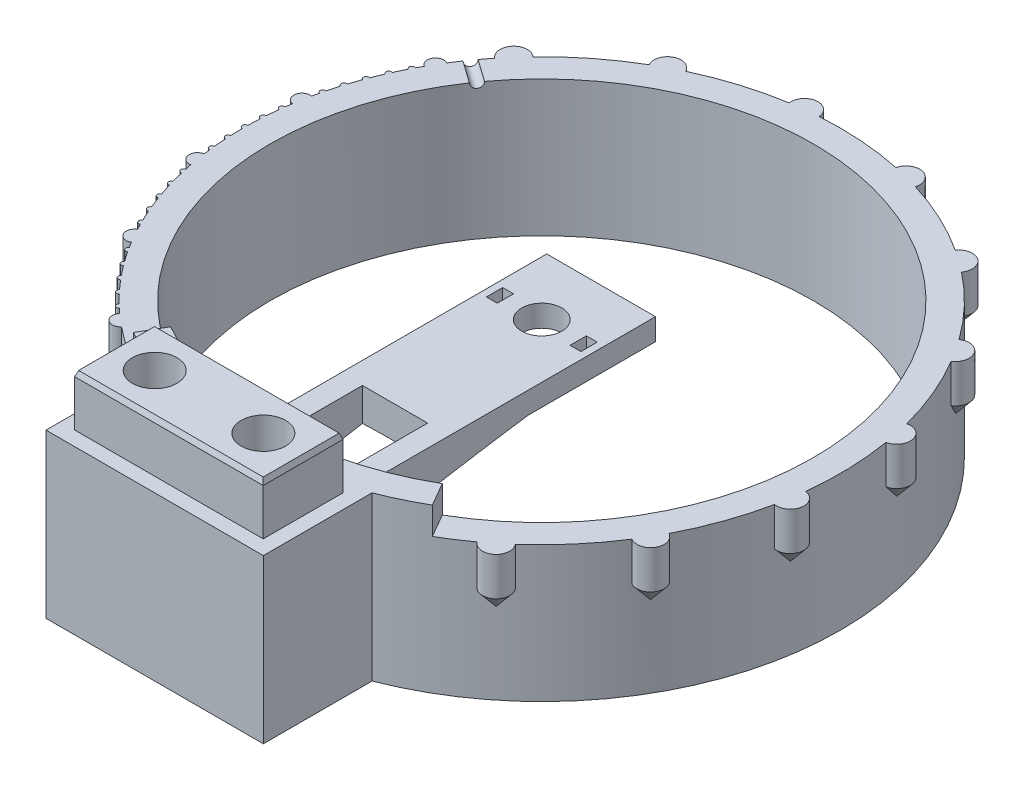
from build123d import *

# Parameters (mm, degrees)
SKETCH1_R              = 55
BOSS_EXTRUDE1_DEPTH    = 30
SKETCH6_R              = 50
CUT_EXTRUDE3_DEPTH     = 31
CUT_EXTRUDE4_DEPTH     = 5
BOSS_EXTRUDE3_START    = -7
BOSS_EXTRUDE3_DEPTH    = 4
SKETCH9_W              = 40
SKETCH9_H              = 20
BOSS_EXTRUDE4_DEPTH    = 30
SKETCH10_R             = 3.7
SKETCH10_W             = 2
SKETCH10_H             = 3
CUT_EXTRUDE5_DEPTH     = 23
CHAMFER2_SIZE          = 6
CHAMFER2_SIZE2         = 34.027690918
SKETCH11_R             = 4.1
CUT_EXTRUDE6_DEPTH     = 31
SKETCH12_R             = 1.5
SKETCH12_R_2           = 0.5
SKETCH12_R_3           = 2.5
BOSS_EXTRUDE5_DEPTH    = 10
SKETCH14_W             = 12
SKETCH14_H             = 20
CUT_EXTRUDE7_DEPTH     = 23.0000001
SKETCH15_W             = 34.7
SKETCH15_H             = 14.7
SKETCH15_R             = 4.1
BOSS_EXTRUDE6_DEPTH    = 9.5
CHAMFER3_SIZE          = 1
CHAMFER3_SIZE2         = 0.363970234
CHAMFER3_PART_2_SIZE   = 1
CHAMFER3_PART_2_SIZE2  = 0.363970234
CHAMFER3_PART_3_SIZE   = 1
CHAMFER3_PART_3_SIZE2  = 0.363970234
CHAMFER3_PART_4_SIZE   = 1
CHAMFER3_PART_4_SIZE2  = 0.363970234
SKETCH16_W             = 35
SKETCH16_H             = 15
CUT_EXTRUDE8_DEPTH     = 10
CHAMFER4_SIZE          = 1
CHAMFER4_SIZE2         = 2.747477419
CHAMFER5_SIZE          = 2.45
CHAMFER5_SIZE2         = 2.919796302
CHAMFER5_PART_2_SIZE   = 2.45
CHAMFER5_PART_2_SIZE2  = 2.919796302
CHAMFER5_PART_3_SIZE   = 2.45
CHAMFER5_PART_3_SIZE2  = 2.919796302
CHAMFER5_PART_4_SIZE   = 2.45
CHAMFER5_PART_4_SIZE2  = 2.919796302
CHAMFER5_PART_5_SIZE   = 2.45
CHAMFER5_PART_5_SIZE2  = 2.919796302
CHAMFER5_PART_6_SIZE   = 2.45
CHAMFER5_PART_6_SIZE2  = 2.919796302
CHAMFER5_PART_7_SIZE   = 2.45
CHAMFER5_PART_7_SIZE2  = 2.919796302
CHAMFER5_PART_8_SIZE   = 2.45
CHAMFER5_PART_8_SIZE2  = 2.919796302
CHAMFER5_PART_9_SIZE   = 2.45
CHAMFER5_PART_9_SIZE2  = 2.919796302
CHAMFER5_PART_10_SIZE  = 2.45
CHAMFER5_PART_10_SIZE2 = 2.919796302


with BuildPart() as part:
    # Sketch1 → Boss-Extrude1 (new body)
    with BuildSketch(Plane(origin=(0, 0, 0), x_dir=(1, 0, 0), z_dir=(0, 1, 0))):
        with Locations(Location((0, 0, 0), (0, 0, 270))):  # turned: the seam where the file's is
            Circle(SKETCH1_R)
    extrude(amount=BOSS_EXTRUDE1_DEPTH)

    # Sketch6 → Cut-Extrude3 (cut, through all)
    with BuildSketch(Plane(origin=(0, 30, 0), x_dir=(1, 0, 0), z_dir=(0, 1, 0))):
        with Locations(Location((0, 0, 0), (0, 0, 270))):  # turned: the seam where the file's is
            Circle(SKETCH6_R)
    extrude(amount=-CUT_EXTRUDE3_DEPTH, mode=Mode.SUBTRACT)

    # Sketch7 → Cut-Extrude4 (cut)
    with BuildSketch(Plane(origin=(0, 30, 0), x_dir=(1, 0, 0), z_dir=(0, 1, 0))):
        with BuildLine():
            Line((-25, -43.301270189), (-27.5, -47.631397208))
            ThreePointArc((-27.5, -47.631397208), (0, 55), (27.5, -47.631397208))
            Line((27.5, -47.631397208), (25, -43.301270189))
            ThreePointArc((25, -43.301270189), (0, 50), (-25, -43.301270189))
        make_face()
    extrude(amount=-CUT_EXTRUDE4_DEPTH, mode=Mode.SUBTRACT)

    # Sketch8 → Boss-Extrude3 (add)
    with BuildSketch(Plane(origin=(0, 25, 0), x_dir=(1, 0, 0), z_dir=(0, 1, 0)).offset(BOSS_EXTRUDE3_START)):
        with BuildLine():
            Line((10, -54.083269132), (10, 10.916730868))
            Line((10, 10.916730868), (-10, 10.916730868))
            Line((-10, 10.916730868), (-10, -54.083269132))
            ThreePointArc((-10, -54.083269132), (0, -55), (10, -54.083269132))
        make_face()
    extrude(amount=BOSS_EXTRUDE3_DEPTH)

    # Sketch9 → Boss-Extrude4 (add)
    with BuildSketch(Plane.XZ):
        with Locations((0, 61.23475383)):
            Rectangle(SKETCH9_W, SKETCH9_H)
    extrude(amount=-BOSS_EXTRUDE4_DEPTH)

    # Sketch10 → Cut-Extrude5 (cut, through all)
    with BuildSketch(Plane(origin=(0, 22, 0), x_dir=(1, 0, 0), z_dir=(0, 1, 0))):
        with Locations(Location((0, 0, 0), (0, 0, 270))):  # turned: the seam where the file's is
            Circle(SKETCH10_R)
        with Locations((7.7, 0)):
            Rectangle(SKETCH10_W, SKETCH10_H)
        with Locations((-7.7, 0)):
            Rectangle(SKETCH10_W, SKETCH10_H)
    extrude(amount=-CUT_EXTRUDE5_DEPTH, mode=Mode.SUBTRACT)

    # Chamfer2
    chamfer2_edges = [part.edges().sort_by_distance(p)[0] for p in [
        (5.0254481, 18, 49.74680765),
    ]]
    chamfer2_side = [part.faces().sort_by_distance(p)[0] for p in [
        (0, 15, -50),
    ]]
    chamfer(chamfer2_edges, length=CHAMFER2_SIZE, length2=CHAMFER2_SIZE2, reference=chamfer2_side[0])

    # Sketch11 → Cut-Extrude6 (cut, through all)
    with BuildSketch(Plane(origin=(0, 30, 0), x_dir=(1, 0, 0), z_dir=(0, 1, 0))):
        with Locations(Location((-10, -61.23475383, 0), (0, 0, 270))):  # turned: the seam where the file's is
            Circle(SKETCH11_R)
        with Locations(Location((10, -61.23475383, 0), (0, 0, 270))):  # turned: the seam where the file's is
            Circle(SKETCH11_R)
    extrude(amount=-CUT_EXTRUDE6_DEPTH, mode=Mode.SUBTRACT)

    # Sketch12 → Boss-Extrude5 (add)
    with BuildSketch(Plane(origin=(0, 25, 0), x_dir=(1, 0, 0), z_dir=(0, 1, 0))):
        with Locations((-35.669848164, -41.864805409)):
            Circle(SKETCH12_R)
        with Locations((-47.837299851, -27.140242132)):
            Circle(SKETCH12_R)
        with Locations((-54.234867172, -9.142165107)):
            Circle(SKETCH12_R)
        with Locations((-54.090909091, 9.958591955)):
            Circle(SKETCH12_R)
        with Locations((-47.422789077, 27.858195853)):
            Circle(SKETCH12_R)
        with Locations((-38.043722374, -39.719959566)):
            Circle(SKETCH12_R_2)
        with Locations((-40.288868671, -37.440713952)):
            Circle(SKETCH12_R_2)
        with Locations((-42.397690188, -35.034780814)):
            Circle(SKETCH12_R_2)
        with Locations((-44.363051343, -32.510301068)):
            Circle(SKETCH12_R_2)
        with Locations((-46.178301975, -29.875816753)):
            Circle(SKETCH12_R_2)
        with Locations((-49.334431446, -24.312833523)):
            Circle(SKETCH12_R_2)
        with Locations((-50.664630942, -21.403157981)):
            Circle(SKETCH12_R_2)
        with Locations((-51.823397364, -18.421060927)):
            Circle(SKETCH12_R_2)
        with Locations((-52.806809814, -15.376632834)):
            Circle(SKETCH12_R_2)
        with Locations((-53.611540735, -12.280175083)):
            Circle(SKETCH12_R_2)
        with Locations((-54.674679987, -5.973220938)):
            Circle(SKETCH12_R_2)
        with Locations((-54.929490991, -2.78406528)):
            Circle(SKETCH12_R_2)
        with Locations((-54.998437985, 0.414510774)):
            Circle(SKETCH12_R_2)
        with Locations((-54.881287675, 3.611684254)):
            Circle(SKETCH12_R_2)
        with Locations((-54.578436459, 6.796636939)):
            Circle(SKETCH12_R_2)
        with Locations((-53.420355208, 13.086850248)):
            Circle(SKETCH12_R_2)
        with Locations((-52.569043754, 16.170826782)):
            Circle(SKETCH12_R_2)
        with Locations((-51.539855295, 19.200086358)):
            Circle(SKETCH12_R_2)
        with Locations((-50.336272281, 22.164378919)):
            Circle(SKETCH12_R_2)
        with Locations((-48.962367255, 25.053674238)):
            Circle(SKETCH12_R_2)
        with Locations((-41.383539223, 36.227098716)):
            Circle(SKETCH12_R_3)
        with Locations((-25.557835394, 48.701099064)):
            Circle(SKETCH12_R_3)
        with Locations((-6.301437111, 54.637824722)):
            Circle(SKETCH12_R_3)
        with Locations((13.8008194, 53.240373627)):
            Circle(SKETCH12_R_3)
        with Locations((32.05055617, 44.696329258)):
            Circle(SKETCH12_R_3)
        with Locations((45.998063758, 30.152580826)):
            Circle(SKETCH12_R_3)
        with Locations((53.771132088, 11.561373358)):
            Circle(SKETCH12_R_3)
        with Locations((54.326362062, -8.581747205)):
            Circle(SKETCH12_R_3)
        with Locations((47.589223722, -27.57291761)):
            Circle(SKETCH12_R_3)
        with Locations((34.4640606, -42.862903856)):
            Circle(SKETCH12_R_3)
    extrude(amount=-BOSS_EXTRUDE5_DEPTH)

    # Sketch13 → Cut-Revolve1 (revolve, cut)
    with BuildSketch(Plane(origin=(0, 25, 0), x_dir=(1, 0, 0), z_dir=(0, 1, 0))):
        Polygon((-38.04336201, 25.705402511), (-46.205304558, 31.483178366), (-45.627526973, 32.299372621), (-37.465584424, 26.521596766), align=None)
    revolve(axis=Axis((-44.890684017, 25, -31.777767205), (0.816194255, 0, 0.577777586)), mode=Mode.SUBTRACT)

    # Sketch14 → Cut-Extrude7 (cut, through all)
    with BuildSketch(Plane(origin=(0, 22, 0), x_dir=(1, 0, 0), z_dir=(0, 1, 0))):
        with Locations((0, -37)):
            Rectangle(SKETCH14_W, SKETCH14_H)
    extrude(amount=-CUT_EXTRUDE7_DEPTH, mode=Mode.SUBTRACT)

    # Sketch15 → Boss-Extrude6 (add)
    with BuildSketch(Plane(origin=(0, 30, 0), x_dir=(1, 0, 0), z_dir=(0, 1, 0))):
        with Locations((-0.026221239, -61.23475383)):
            Rectangle(SKETCH15_W, SKETCH15_H)
        with Locations(Location((-10, -61.23475383, 0), (0, 0, 270))):  # turned: the seam where the file's is
            Circle(SKETCH15_R, mode=Mode.SUBTRACT)
        with Locations(Location((10, -61.23475383, 0), (0, 0, 270))):  # turned: the seam where the file's is
            Circle(SKETCH15_R, mode=Mode.SUBTRACT)
    extrude(amount=BOSS_EXTRUDE6_DEPTH)

    # Chamfer3
    chamfer3_edges = [part.edges().sort_by_distance(p)[0] for p in [
        (-17.376221239, 39.5, 61.23475383),
    ]]
    chamfer3_side = [part.faces().sort_by_distance(p)[0] for p in [
        (-17.376221239, 34.75, 61.23475383),
    ]]
    chamfer(chamfer3_edges, length=CHAMFER3_SIZE, length2=CHAMFER3_SIZE2, reference=chamfer3_side[0])

    # Chamfer3 part 2
    chamfer3_part_2_edges = [part.edges().sort_by_distance(p)[0] for p in [
        (-0.026221239, 39.5, 68.58475383),
    ]]
    chamfer3_part_2_side = [part.faces().sort_by_distance(p)[0] for p in [
        (-0.026221239, 34.75, 68.58475383),
    ]]
    chamfer(chamfer3_part_2_edges, length=CHAMFER3_PART_2_SIZE, length2=CHAMFER3_PART_2_SIZE2, reference=chamfer3_part_2_side[0])

    # Chamfer3 part 3
    chamfer3_part_3_edges = [part.edges().sort_by_distance(p)[0] for p in [
        (17.323778761, 39.5, 61.23475383),
    ]]
    chamfer3_part_3_side = [part.faces().sort_by_distance(p)[0] for p in [
        (17.323778761, 34.75, 61.23475383),
    ]]
    chamfer(chamfer3_part_3_edges, length=CHAMFER3_PART_3_SIZE, length2=CHAMFER3_PART_3_SIZE2, reference=chamfer3_part_3_side[0])

    # Chamfer3 part 4
    chamfer3_part_4_edges = [part.edges().sort_by_distance(p)[0] for p in [
        (-0.026221239, 39.5, 53.88475383),
    ]]
    chamfer3_part_4_side = [part.faces().sort_by_distance(p)[0] for p in [
        (-0.026221239, 34.75, 53.88475383),
    ]]
    chamfer(chamfer3_part_4_edges, length=CHAMFER3_PART_4_SIZE, length2=CHAMFER3_PART_4_SIZE2, reference=chamfer3_part_4_side[0])

    # Sketch16 → Cut-Extrude8 (cut)
    with BuildSketch(Plane.XZ):
        with Locations((0, 61.23475383)):
            Rectangle(SKETCH16_W, SKETCH16_H)
    extrude(amount=-CUT_EXTRUDE8_DEPTH, mode=Mode.SUBTRACT)

    # Chamfer4
    chamfer4_edges = [part.edges().sort_by_distance(p)[0] for p in [
        (17.5, 0, 61.23475383),
        (0, 0, 68.73475383),
        (-17.5, 0, 61.23475383),
        (0, 0, 53.73475383),
    ]]
    chamfer4_side = [part.faces().sort_by_distance(p)[0] for p in [
        (-18.325628086, 0, 61.23475383),
    ]]
    chamfer(chamfer4_edges, length=CHAMFER4_SIZE, length2=CHAMFER4_SIZE2, reference=chamfer4_side[0])

    # Chamfer5
    chamfer5_edges = [part.edges().sort_by_distance(p)[0] for p in [
        (-43.264609188, 15, -37.873785021),
    ]]
    chamfer5_side = [part.faces().sort_by_distance(p)[0] for p in [
        (-42.174140054, 15, -36.919189699),
    ]]
    chamfer(chamfer5_edges, length=CHAMFER5_SIZE, length2=CHAMFER5_SIZE2, reference=chamfer5_side[0])

    # Chamfer5 part 2
    chamfer5_part_2_edges = [part.edges().sort_by_distance(p)[0] for p in [
        (-26.719555184, 15, -50.914785385),
    ]]
    chamfer5_part_2_side = [part.faces().sort_by_distance(p)[0] for p in [
        (-26.04609827, 15, -49.631496272),
    ]]
    chamfer(chamfer5_part_2_edges, length=CHAMFER5_PART_2_SIZE, length2=CHAMFER5_PART_2_SIZE2, reference=chamfer5_part_2_side[0])

    # Chamfer5 part 3
    chamfer5_part_3_edges = [part.edges().sort_by_distance(p)[0] for p in [
        (-6.58786607, 15, -57.121362209),
    ]]
    chamfer5_part_3_side = [part.faces().sort_by_distance(p)[0] for p in [
        (-6.421821242, 15, -55.681638528),
    ]]
    chamfer(chamfer5_part_3_edges, length=CHAMFER5_PART_3_SIZE, length2=CHAMFER5_PART_3_SIZE2, reference=chamfer5_part_3_side[0])

    # Chamfer5 part 4
    chamfer5_part_4_edges = [part.edges().sort_by_distance(p)[0] for p in [
        (14.428129372, 15, -55.66039061),
    ]]
    chamfer5_part_4_side = [part.faces().sort_by_distance(p)[0] for p in [
        (14.064473487, 15, -54.2574902),
    ]]
    chamfer(chamfer5_part_4_edges, length=CHAMFER5_PART_4_SIZE, length2=CHAMFER5_PART_4_SIZE2, reference=chamfer5_part_4_side[0])

    # Chamfer5 part 5
    chamfer5_part_5_edges = [part.edges().sort_by_distance(p)[0] for p in [
        (33.507399633, 15, -46.727980588),
    ]]
    chamfer5_part_5_side = [part.faces().sort_by_distance(p)[0] for p in [
        (32.662857506, 15, -45.550218406),
    ]]
    chamfer(chamfer5_part_5_edges, length=CHAMFER5_PART_5_SIZE, length2=CHAMFER5_PART_5_SIZE2, reference=chamfer5_part_5_side[0])

    # Chamfer5 part 6
    chamfer5_part_6_edges = [part.edges().sort_by_distance(p)[0] for p in [
        (48.088884838, 15, -31.523152682),
    ]]
    chamfer5_part_6_side = [part.faces().sort_by_distance(p)[0] for p in [
        (46.876821547, 15, -30.728622796),
    ]]
    chamfer(chamfer5_part_6_edges, length=CHAMFER5_PART_6_SIZE, length2=CHAMFER5_PART_6_SIZE2, reference=chamfer5_part_6_side[0])

    # Chamfer5 part 7
    chamfer5_part_7_edges = [part.edges().sort_by_distance(p)[0] for p in [
        (56.215274456, 15, -12.086890329),
    ]]
    chamfer5_part_7_side = [part.faces().sort_by_distance(p)[0] for p in [
        (54.798388396, 15, -11.782244544),
    ]]
    chamfer(chamfer5_part_7_edges, length=CHAMFER5_PART_7_SIZE, length2=CHAMFER5_PART_7_SIZE2, reference=chamfer5_part_7_side[0])

    # Chamfer5 part 8
    chamfer5_part_8_edges = [part.edges().sort_by_distance(p)[0] for p in [
        (56.795742156, 15, 8.971826624),
    ]]
    chamfer5_part_8_side = [part.faces().sort_by_distance(p)[0] for p in [
        (55.364225613, 15, 8.745694915),
    ]]
    chamfer(chamfer5_part_8_edges, length=CHAMFER5_PART_8_SIZE, length2=CHAMFER5_PART_8_SIZE2, reference=chamfer5_part_8_side[0])

    # Chamfer5 part 9
    chamfer5_part_9_edges = [part.edges().sort_by_distance(p)[0] for p in [
        (49.752370255, 15, 28.826232047),
    ]]
    chamfer5_part_9_side = [part.faces().sort_by_distance(p)[0] for p in [
        (48.498379403, 15, 28.099677089),
    ]]
    chamfer(chamfer5_part_9_edges, length=CHAMFER5_PART_9_SIZE, length2=CHAMFER5_PART_9_SIZE2, reference=chamfer5_part_9_side[0])

    # Chamfer5 part 10
    chamfer5_part_10_edges = [part.edges().sort_by_distance(p)[0] for p in [
        (36.030608809, 15, 44.811217668),
    ]]
    chamfer5_part_10_side = [part.faces().sort_by_distance(p)[0] for p in [
        (35.122470089, 15, 43.681766815),
    ]]
    chamfer(chamfer5_part_10_edges, length=CHAMFER5_PART_10_SIZE, length2=CHAMFER5_PART_10_SIZE2, reference=chamfer5_part_10_side[0])


solid = part.part
